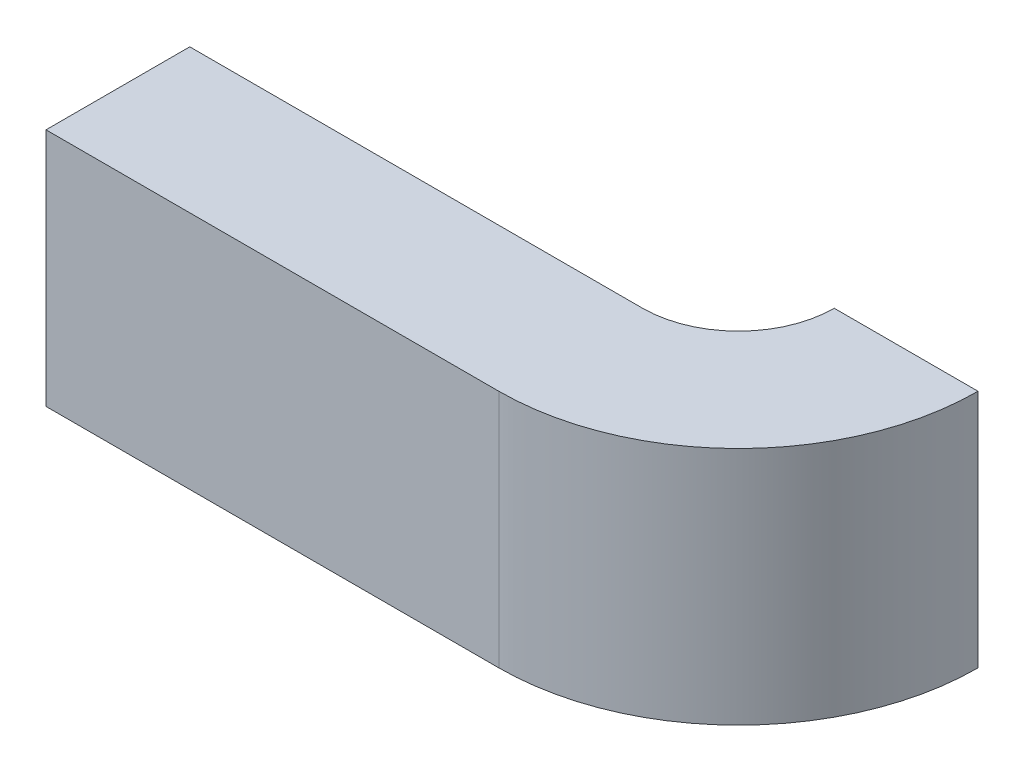
from build123d import *

# Parameters (mm, degrees)
BOSS_EXTRUDE1_DEPTH = 0.25


with BuildPart() as part:
    # Sketch3 → Boss-Extrude1 (new body, symmetric)
    with BuildSketch(Plane(origin=(0, 0, 0), x_dir=(1, 0, 0), z_dir=(0, 1, 0))):
        with BuildLine():
            Line((0, -0.15), (0.945, -0.15))
            ThreePointArc((0.945, -0.15), (1.298553391, -0.003553391), (1.445, 0.35))
            Line((1.445, 0.35), (1.145, 0.35))
            ThreePointArc((1.145, 0.35), (1.086421356, 0.208578644), (0.945, 0.15))
            Line((0.945, 0.15), (0, 0.15))
            Line((0, 0.15), (0, -0.15))
        make_face()
    extrude(amount=BOSS_EXTRUDE1_DEPTH, both=True)


solid = part.part
